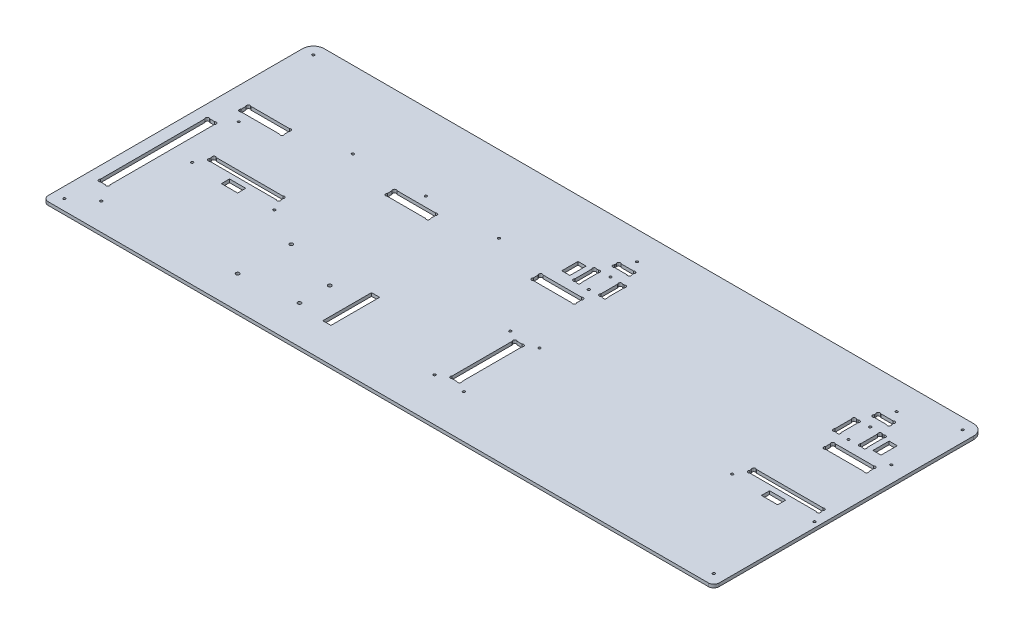
from build123d import *

# Parameters (mm, degrees)
ESQUISSE1_R             = 1.1
EXTRUSION1_DEPTH        = 3
ESQUISSE3_R             = 1.1
ENL_V_MAT_EXTRU_2_DEPTH = 4
CONG_1_R                = 5
ESQUISSE4_R             = 1.1
ENL_V_MAT_EXTRU_3_DEPTH = 4
ESQUISSE5_R             = 1.59
ENL_V_MAT_EXTRU_4_DEPTH = 4
ESQUISSE6_W             = 15
ESQUISSE6_H             = 7.5
ESQUISSE6_W_2           = 7.5
ESQUISSE6_H_2           = 15
ESQUISSE6_H_3           = 45
ENL_V_MAT_EXTRU_5_DEPTH = 4
ESQUISSE7_R             = 1.1
ENL_V_MAT_EXTRU_6_DEPTH = 4


with BuildPart() as part:
    # Esquisse1 → Extrusion1 (new body)
    with BuildSketch(Plane(origin=(0, 0, 0), x_dir=(1, 0, 0), z_dir=(0, 1, 0))):
        with BuildLine():
            Line((10, 250), (610, 250))
            ThreePointArc((610, 250), (617.071067812, 247.071067812), (620, 240))
            Line((620, 240), (620, 0))
            Line((620, 0), (0, 0))
            Line((0, 0), (0, 240))
            ThreePointArc((0, 240), (2.928932188, 247.071067812), (10, 250))
        make_face()
        with Locations(Location((539, 98, 0), (0, 0, 270))):  # turned: the seam where the file's is
            Circle(ESQUISSE1_R, mode=Mode.SUBTRACT)
        with Locations(Location((615, 98, 0), (0, 0, 270))):  # turned: the seam where the file's is
            Circle(ESQUISSE1_R, mode=Mode.SUBTRACT)
        with BuildLine():
            Line((317, 211.2627417), (317, 212.7372583))
            ThreePointArc((317, 212.7372583), (317, 215), (319.2627417, 215))
            Line((319.2627417, 215), (330.7372583, 215))
            ThreePointArc((330.7372583, 215), (333, 215), (333, 212.7372583))
            Line((333, 212.7372583), (333, 211.2627417))
            ThreePointArc((333, 211.2627417), (333, 209), (330.737258301, 209))
            Line((330.737258301, 209), (319.262741699, 209))
            ThreePointArc((319.262741699, 209), (316.999999999, 209.000000001), (317, 211.2627417))
        make_face(mode=Mode.SUBTRACT)
        with BuildLine():
            Line((312.262741699, 179.5), (313.737258301, 179.5))
            ThreePointArc((313.737258301, 179.5), (316.000000001, 179.500000001), (316, 181.762741701))
            Line((316, 181.762741701), (316, 197.237258299))
            ThreePointArc((316, 197.237258299), (316.000000001, 199.499999999), (313.737258301, 199.5))
            Line((313.737258301, 199.5), (312.262741699, 199.5))
            ThreePointArc((312.262741699, 199.5), (309.999999999, 199.499999999), (310, 197.237258299))
            Line((310, 197.237258299), (310, 181.762741701))
            ThreePointArc((310, 181.762741701), (309.999999999, 179.500000001), (312.262741699, 179.5))
        make_face(mode=Mode.SUBTRACT)
        with BuildLine():
            Line((334, 181.762741701), (334, 197.2372583))
            ThreePointArc((334, 197.2372583), (334, 199.5), (336.2627417, 199.5))
            Line((336.2627417, 199.5), (337.7372583, 199.5))
            ThreePointArc((337.7372583, 199.5), (340, 199.5), (340, 197.2372583))
            Line((340, 197.2372583), (340, 181.762741701))
            ThreePointArc((340, 181.762741701), (340.000000001, 179.500000001), (337.737258301, 179.5))
            Line((337.737258301, 179.5), (336.262741699, 179.5))
            ThreePointArc((336.262741699, 179.5), (333.999999999, 179.500000001), (334, 181.762741701))
        make_face(mode=Mode.SUBTRACT)
        with BuildLine():
            Line((552.2627417, 179.5), (553.7372583, 179.5))
            ThreePointArc((553.7372583, 179.5), (556, 179.5), (556, 181.7627417))
            Line((556, 181.7627417), (556, 197.2372583))
            ThreePointArc((556, 197.2372583), (556, 199.5), (553.7372583, 199.5))
            Line((553.7372583, 199.5), (552.2627417, 199.5))
            ThreePointArc((552.2627417, 199.5), (550, 199.5), (550, 197.2372583))
            Line((550, 197.2372583), (550, 181.7627417))
            ThreePointArc((550, 181.7627417), (550, 179.5), (552.2627417, 179.5))
        make_face(mode=Mode.SUBTRACT)
        with BuildLine():
            Line((574, 181.7627417), (574, 197.2372583))
            ThreePointArc((574, 197.2372583), (574, 199.5), (576.2627417, 199.5))
            Line((576.2627417, 199.5), (577.7372583, 199.5))
            ThreePointArc((577.7372583, 199.5), (580, 199.5), (580, 197.2372583))
            Line((580, 197.2372583), (580, 181.7627417))
            ThreePointArc((580, 181.7627417), (580, 179.5), (577.7372583, 179.5))
            Line((577.7372583, 179.5), (576.2627417, 179.5))
            ThreePointArc((576.2627417, 179.5), (574, 179.5), (574, 181.7627417))
        make_face(mode=Mode.SUBTRACT)
        with BuildLine():
            Line((559.2627417, 209), (570.7372583, 209))
            ThreePointArc((570.7372583, 209), (573, 209), (573, 211.2627417))
            Line((573, 211.2627417), (573, 212.7372583))
            ThreePointArc((573, 212.7372583), (573, 215), (570.7372583, 215))
            Line((570.7372583, 215), (559.2627417, 215))
            ThreePointArc((559.2627417, 215), (557, 215), (557, 212.7372583))
            Line((557, 212.7372583), (557, 211.2627417))
            ThreePointArc((557, 211.2627417), (557, 209), (559.2627417, 209))
        make_face(mode=Mode.SUBTRACT)
        with BuildLine():
            Line((560, 167.7372583), (560, 163.2627417))
            ThreePointArc((560, 163.2627417), (560, 161), (562.2627417, 161))
            Line((562.2627417, 161), (597.7372583, 161))
            ThreePointArc((597.7372583, 161), (600, 161), (600, 163.2627417))
            Line((600, 163.2627417), (600, 167.7372583))
            ThreePointArc((600, 167.7372583), (600, 170), (597.7372583, 170))
            Line((597.7372583, 170), (562.2627417, 170))
            ThreePointArc((562.2627417, 170), (560, 170), (560, 167.7372583))
        make_face(mode=Mode.SUBTRACT)
        with BuildLine():
            Line((292.2627417, 161), (327.7372583, 161))
            ThreePointArc((327.7372583, 161), (330, 161), (330, 163.2627417))
            Line((330, 163.2627417), (330, 167.7372583))
            ThreePointArc((330, 167.7372583), (330, 170), (327.7372583, 170))
            Line((327.7372583, 170), (292.2627417, 170))
            ThreePointArc((292.2627417, 170), (290, 170), (290, 167.7372583))
            Line((290, 167.7372583), (290, 163.2627417))
            ThreePointArc((290, 163.2627417), (290, 161), (292.2627417, 161))
        make_face(mode=Mode.SUBTRACT)
        with BuildLine():
            Line((20, 167.7372583), (20, 163.2627417))
            ThreePointArc((20, 163.2627417), (20, 161), (22.2627417, 161))
            Line((22.2627417, 161), (57.7372583, 161))
            ThreePointArc((57.7372583, 161), (60, 161), (60, 163.2627417))
            Line((60, 163.2627417), (60, 167.7372583))
            ThreePointArc((60, 167.7372583), (60, 170), (57.7372583, 170))
            Line((57.7372583, 170), (22.2627417, 170))
            ThreePointArc((22.2627417, 170), (20, 170), (20, 167.7372583))
        make_face(mode=Mode.SUBTRACT)
        with BuildLine():
            Line((155, 167.7372583), (155, 163.2627417))
            ThreePointArc((155, 163.2627417), (155, 161), (157.2627417, 161))
            Line((157.2627417, 161), (192.7372583, 161))
            ThreePointArc((192.7372583, 161), (195, 161), (195, 163.2627417))
            Line((195, 163.2627417), (195, 167.7372583))
            ThreePointArc((195, 167.7372583), (195, 170), (192.7372583, 170))
            Line((192.7372583, 170), (157.2627417, 170))
            ThreePointArc((157.2627417, 170), (155, 170), (155, 167.7372583))
        make_face(mode=Mode.SUBTRACT)
        with BuildLine():
            Line((13.2627417, 40), (17.7372583, 40))
            ThreePointArc((17.7372583, 40), (20, 40), (20, 42.2627417))
            Line((20, 42.2627417), (20, 138.7372583))
            ThreePointArc((20, 138.7372583), (20, 141), (17.7372583, 141))
            Line((17.7372583, 141), (13.2627417, 141))
            ThreePointArc((13.2627417, 141), (11, 141), (11, 138.7372583))
            Line((11, 138.7372583), (11, 42.2627417))
            ThreePointArc((11, 42.2627417), (11, 40), (13.2627417, 40))
        make_face(mode=Mode.SUBTRACT)
        with BuildLine():
            Line((337.7372583, 45), (333.2627417, 45))
            ThreePointArc((333.2627417, 45), (331, 45), (331, 47.2627417))
            Line((331, 47.2627417), (331, 102.7372583))
            ThreePointArc((331, 102.7372583), (331, 105), (333.2627417, 105))
            Line((333.2627417, 105), (337.7372583, 105))
            ThreePointArc((337.7372583, 105), (340, 105), (340, 102.7372583))
            Line((340, 102.7372583), (340, 47.2627417))
            ThreePointArc((340, 47.2627417), (340, 45), (337.7372583, 45))
        make_face(mode=Mode.SUBTRACT)
        with BuildLine():
            Line((610, 109.2627417), (610, 110.7372583))
            ThreePointArc((610, 110.7372583), (610, 113), (607.7372583, 113))
            Line((607.7372583, 113), (546.2627417, 113))
            ThreePointArc((546.2627417, 113), (544, 113), (544, 110.7372583))
            Line((544, 110.7372583), (544, 109.2627417))
            ThreePointArc((544, 109.2627417), (544, 107), (546.2627417, 107))
            Line((546.2627417, 107), (607.7372583, 107))
            ThreePointArc((607.7372583, 107), (610, 107), (610, 109.2627417))
        make_face(mode=Mode.SUBTRACT)
        with BuildLine():
            Line((108.7372583, 113), (47.2627417, 113))
            ThreePointArc((47.2627417, 113), (45, 113), (45, 110.7372583))
            Line((45, 110.7372583), (45, 109.2627417))
            ThreePointArc((45, 109.2627417), (45, 107), (47.2627417, 107))
            Line((47.2627417, 107), (108.7372583, 107))
            ThreePointArc((108.7372583, 107), (111, 107), (111, 109.2627417))
            Line((111, 109.2627417), (111, 110.7372583))
            ThreePointArc((111, 110.7372583), (111, 113), (108.7372583, 113))
        make_face(mode=Mode.SUBTRACT)
    extrude(amount=EXTRUSION1_DEPTH)

    # Esquisse3 → Enlèv. mat.-Extru.2 (cut, through all)
    with BuildSketch(Plane(origin=(0, 3, 0), x_dir=(1, 0, 0), z_dir=(0, 1, 0))):
        with Locations(Location((565, 179.5, 0), (0, 0, 270))):  # turned: the seam where the file's is
            Circle(ESQUISSE3_R)
        with Locations(Location((565, 199.5, 0), (0, 0, 270))):  # turned: the seam where the file's is
            Circle(ESQUISSE3_R)
        with Locations(Location((325, 179.5, 0), (0, 0, 270))):  # turned: the seam where the file's is
            Circle(ESQUISSE3_R)
        with Locations(Location((325, 199.5, 0), (0, 0, 270))):  # turned: the seam where the file's is
            Circle(ESQUISSE3_R)
    extrude(amount=-ENL_V_MAT_EXTRU_2_DEPTH, mode=Mode.SUBTRACT)

    # Congé1
    cong_1_edges = [part.edges().sort_by_distance(p)[0] for p in [
        (620, 1.5, 0),
        (0, 1.5, 0),
    ]]
    fillet(cong_1_edges, radius=CONG_1_R)

    # Esquisse4 → Enlèv. mat.-Extru.3 (cut, through all)
    with BuildSketch(Plane.XZ):
        with Locations(Location((10, -10, 0), (0, 0, 270))):  # turned: the seam where the file's is
            Circle(ESQUISSE4_R)
        with Locations(Location((610, -10, 0), (0, 0, 270))):  # turned: the seam where the file's is
            Circle(ESQUISSE4_R)
        with Locations(Location((610, -240, 0), (0, 0, 270))):  # turned: the seam where the file's is
            Circle(ESQUISSE4_R)
        with Locations(Location((10, -240, 0), (0, 0, 270))):  # turned: the seam where the file's is
            Circle(ESQUISSE4_R)
    extrude(amount=-ENL_V_MAT_EXTRU_3_DEPTH, mode=Mode.SUBTRACT)

    # Esquisse5 → Enlèv. mat.-Extru.4 (cut, through all)
    with BuildSketch(Plane(origin=(0, 3, 0), x_dir=(1, 0, 0), z_dir=(0, 1, 0))):
        with Locations(Location((151.27, 78.26, 0), (0, 0, 270))):  # turned: the seam where the file's is
            Circle(ESQUISSE5_R)
        with Locations(Location((150, 30, 0), (0, 0, 270))):  # turned: the seam where the file's is
            Circle(ESQUISSE5_R)
        with Locations(Location((202.07, 63.02, 0), (0, 0, 270))):  # turned: the seam where the file's is
            Circle(ESQUISSE5_R)
        with Locations(Location((202.07, 35.08, 0), (0, 0, 270))):  # turned: the seam where the file's is
            Circle(ESQUISSE5_R)
    extrude(amount=-ENL_V_MAT_EXTRU_4_DEPTH, mode=Mode.SUBTRACT)

    # Esquisse6 → Enlèv. mat.-Extru.5 (cut, through all)
    with BuildSketch(Plane(origin=(0, 3, 0), x_dir=(1, 0, 0), z_dir=(0, 1, 0))):
        with Locations((577, 98.25)):
            Rectangle(ESQUISSE6_W, ESQUISSE6_H)
        with Locations((588.75, 189.5)):
            Rectangle(ESQUISSE6_W_2, ESQUISSE6_H_2)
        with Locations((301.25, 189.5)):
            Rectangle(ESQUISSE6_W_2, ESQUISSE6_H_2)
        with Locations((230.82, 54.13)):
            Rectangle(ESQUISSE6_W_2, ESQUISSE6_H_3)
        with Locations((78, 98.25)):
            Rectangle(ESQUISSE6_W, ESQUISSE6_H)
    extrude(amount=-ENL_V_MAT_EXTRU_5_DEPTH, mode=Mode.SUBTRACT)

    # Esquisse7 → Enlèv. mat.-Extru.6 (cut, through all)
    with BuildSketch(Plane(origin=(0, 3, 0), x_dir=(1, 0, 0), z_dir=(0, 1, 0))):
        with Locations(Location((349, 110, 0), (0, 0, 270))):  # turned: the seam where the file's is
            Circle(ESQUISSE7_R)
        with Locations(Location((349, 40, 0), (0, 0, 270))):  # turned: the seam where the file's is
            Circle(ESQUISSE7_R)
        with Locations(Location((322, 110, 0), (0, 0, 270))):  # turned: the seam where the file's is
            Circle(ESQUISSE7_R)
        with Locations(Location((322, 40, 0), (0, 0, 270))):  # turned: the seam where the file's is
            Circle(ESQUISSE7_R)
        with Locations(Location((605, 179, 0), (0, 0, 270))):  # turned: the seam where the file's is
            Circle(ESQUISSE7_R)
        with Locations(Location((565, 224, 0), (0, 0, 270))):  # turned: the seam where the file's is
            Circle(ESQUISSE7_R)
        with Locations(Location((325, 224, 0), (0, 0, 270))):  # turned: the seam where the file's is
            Circle(ESQUISSE7_R)
        with Locations(Location((175, 179, 0), (0, 0, 270))):  # turned: the seam where the file's is
            Circle(ESQUISSE7_R)
        with Locations(Location((242.5, 179, 0), (0, 0, 270))):  # turned: the seam where the file's is
            Circle(ESQUISSE7_R)
        with Locations(Location((107.5, 179, 0), (0, 0, 270))):  # turned: the seam where the file's is
            Circle(ESQUISSE7_R)
        with Locations(Location((116, 98, 0), (0, 0, 270))):  # turned: the seam where the file's is
            Circle(ESQUISSE7_R)
        with Locations(Location((40, 98, 0), (0, 0, 270))):  # turned: the seam where the file's is
            Circle(ESQUISSE7_R)
        with Locations(Location((29, 152, 0), (0, 0, 270))):  # turned: the seam where the file's is
            Circle(ESQUISSE7_R)
        with Locations(Location((29, 25, 0), (0, 0, 270))):  # turned: the seam where the file's is
            Circle(ESQUISSE7_R)
    extrude(amount=-ENL_V_MAT_EXTRU_6_DEPTH, mode=Mode.SUBTRACT)


solid = part.part
